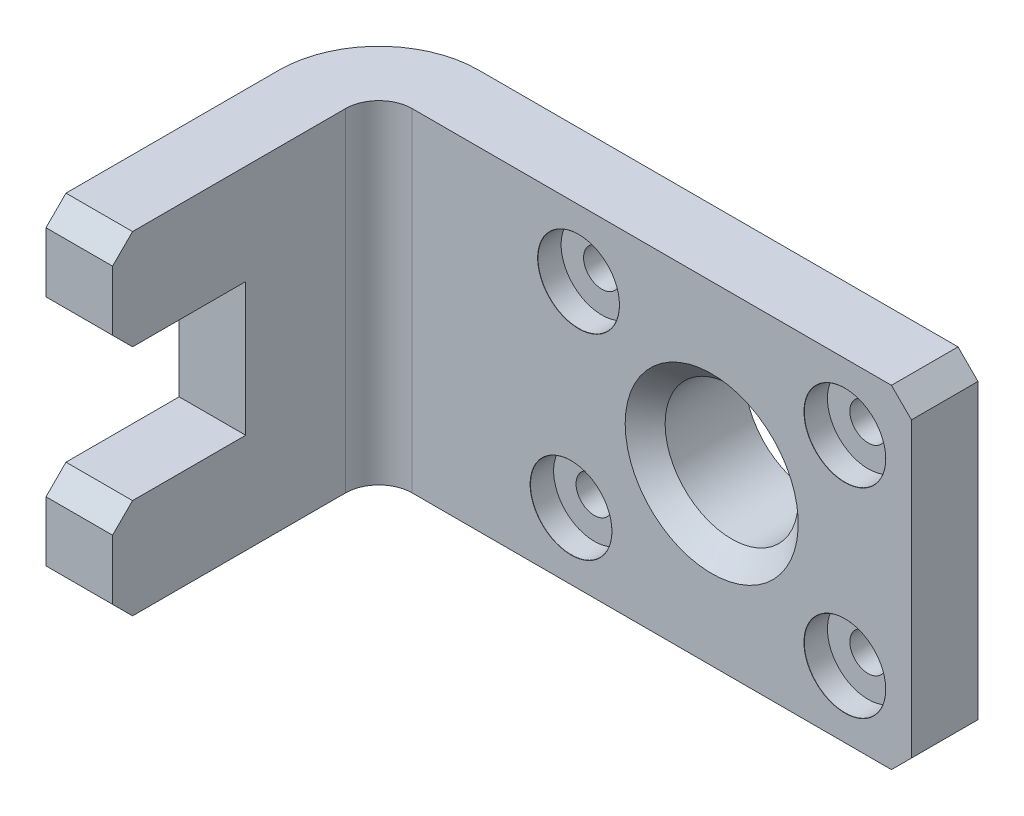
from build123d import *

# Parameters (mm, degrees)
SKETCH1_W                              = 80
SKETCH1_H                              = 50
BOSS_EXTRUDE1_DEPTH                    = 10
SKETCH2_W                              = 50
SKETCH2_H                              = 50
BOSS_EXTRUDE2_DEPTH                    = 10
SKETCH5_W                              = 10
SKETCH5_H                              = 20
CUT_EXTRUDE2_DEPTH                     = 20
SKETCH10_R                             = 15
BOSS_EXTRUDE3_DEPTH                    = 5
SKETCH13_R                             = 10
CUT_EXTRUDE4_DEPTH                     = 15
CHAMFER1_SIZE                          = 3
CBORE_FOR_M5_HEX_HEAD_BOLT2_AT_2_COUNT = 2
CBORE_FOR_M5_HEX_HEAD_BOLT2_AT_2_PITCH = 30
CBORE_FOR_M5_HEX_HEAD_BOLT2_AT_3_COUNT = 2
CBORE_FOR_M5_HEX_HEAD_BOLT2_AT_3_PITCH = 50.908866275
CBORE_FOR_M5_HEX_HEAD_BOLT2_AT_4_COUNT = 2
CBORE_FOR_M5_HEX_HEAD_BOLT2_AT_4_PITCH = 40
CHAMFER2_SIZE                          = 3
CHAMFER3_SIZE                          = 3
CHAMFER4_SIZE                          = 3
FILLET1_R                              = 5
FILLET2_R                              = 15


with BuildPart() as part:
    # Sketch1 → Boss-Extrude1 (new body)
    with BuildSketch(Plane.XY):
        with Locations((40, 25)):
            Rectangle(SKETCH1_W, SKETCH1_H)
    extrude(amount=BOSS_EXTRUDE1_DEPTH)

    # Sketch2 → Boss-Extrude2 (add)
    with BuildSketch(Plane.ZY):
        with Locations((25, 25)):
            Rectangle(SKETCH2_W, SKETCH2_H)
    extrude(amount=BOSS_EXTRUDE2_DEPTH)

    # Sketch5 → Cut-Extrude2 (cut)
    with BuildSketch(Plane.XY.offset(50)):
        with Locations((-5, 25)):
            Rectangle(SKETCH5_W, SKETCH5_H)
    extrude(amount=-CUT_EXTRUDE2_DEPTH, mode=Mode.SUBTRACT)

    # Sketch10 → Boss-Extrude3 (add)
    with BuildSketch(Plane(origin=(0, 0, 0), x_dir=(-1, 0, 0), z_dir=(0, 0, -1))):
        with Locations((-50, 25)):
            Circle(SKETCH10_R)
    extrude(amount=BOSS_EXTRUDE3_DEPTH)

    # Sketch13 → Cut-Extrude4 (cut)
    with BuildSketch(Plane(origin=(0, 0, -5), x_dir=(-1, 0, 0), z_dir=(0, 0, -1))):
        with Locations((-50, 25)):
            Circle(SKETCH13_R)
    extrude(amount=-CUT_EXTRUDE4_DEPTH, mode=Mode.SUBTRACT)

    # Chamfer1
    chamfer1_edges = [part.edges().sort_by_distance(p)[0] for p in [
        (60, 25, 10),
    ]]
    chamfer(chamfer1_edges, length=CHAMFER1_SIZE)

    # Sketch19 → CBORE for M5 Hex Head Bolt2 (revolve, cut)
    with BuildSketch(Plane(origin=(70, 40, 10), x_dir=(0, -1, 0), z_dir=(1, 0, 0))):
        Polygon((0, 0), (0, 15), (2.75, 15), (2.75, 3.5), (6.119, 3.5), (6.119, 0.020977491), (6.144, 0), align=None)
    cbore_for_m5_hex_head_bolt2 = revolve(axis=Axis((70, 40, 16.35), (0, 0, -1)), mode=Mode.SUBTRACT)

    # CBORE for M5 Hex Head Bolt2 at 2: CBORE for M5 Hex Head Bolt2 ×2
    with Locations(*[(0, -i * CBORE_FOR_M5_HEX_HEAD_BOLT2_AT_2_PITCH, 0) for i in range(1, CBORE_FOR_M5_HEX_HEAD_BOLT2_AT_2_COUNT)]):
        add(cbore_for_m5_hex_head_bolt2, mode=Mode.SUBTRACT)

    # CBORE for M5 Hex Head Bolt2 at 3: CBORE for M5 Hex Head Bolt2 ×2
    with Locations(*[Vector(-0.80792282, -0.589288314, 0) * (i * CBORE_FOR_M5_HEX_HEAD_BOLT2_AT_3_PITCH) for i in range(1, CBORE_FOR_M5_HEX_HEAD_BOLT2_AT_3_COUNT)]):
        add(cbore_for_m5_hex_head_bolt2, mode=Mode.SUBTRACT)

    # CBORE for M5 Hex Head Bolt2 at 4: CBORE for M5 Hex Head Bolt2 ×2
    with Locations(*[(-i * CBORE_FOR_M5_HEX_HEAD_BOLT2_AT_4_PITCH, 0, 0) for i in range(1, CBORE_FOR_M5_HEX_HEAD_BOLT2_AT_4_COUNT)]):
        add(cbore_for_m5_hex_head_bolt2, mode=Mode.SUBTRACT)

    # Chamfer2
    chamfer2_edges = [part.edges().sort_by_distance(p)[0] for p in [
        (-5, 50, 50),
    ]]
    chamfer(chamfer2_edges, length=CHAMFER2_SIZE)

    # Chamfer3
    chamfer3_edges = [part.edges().sort_by_distance(p)[0] for p in [
        (-5, 35, 50),
    ]]
    chamfer(chamfer3_edges, length=CHAMFER3_SIZE)

    # Chamfer4
    chamfer4_edges = [part.edges().sort_by_distance(p)[0] for p in [
        (-5, 0, 50),
        (-5, 15, 50),
        (80, 50, 5),
        (80, 0, 5),
    ]]
    chamfer(chamfer4_edges, length=CHAMFER4_SIZE)

    # Fillet1
    fillet1_edges = [part.edges().sort_by_distance(p)[0] for p in [
        (0, 25, 10),
    ]]
    fillet(fillet1_edges, radius=FILLET1_R)

    # Fillet2
    fillet2_edges = [part.edges().sort_by_distance(p)[0] for p in [
        (-10, 25, 0),
    ]]
    fillet(fillet2_edges, radius=FILLET2_R)


solid = part.part
